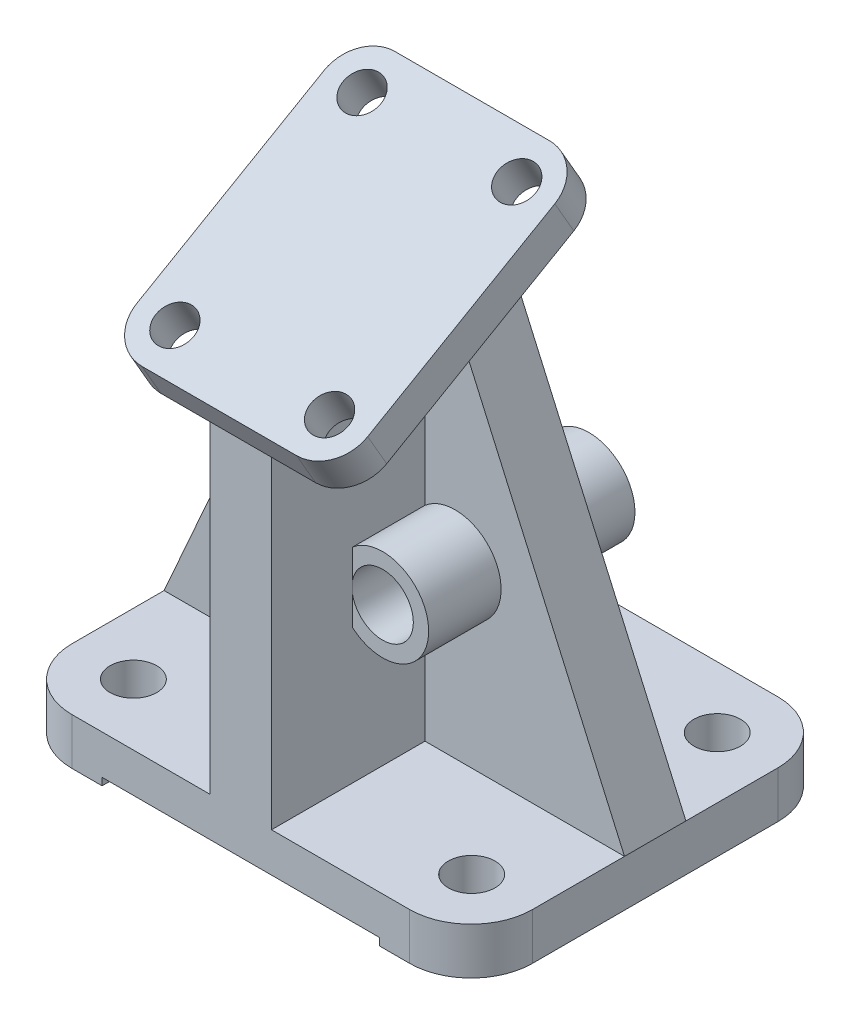
from build123d import *

# Parameters (mm, degrees)
CROQUIS3_W               = 95.25
CROQUIS3_H               = 76.2
SALIENTE_EXTRUIR1_DEPTH  = 9.652
REDONDEO1_R              = 12.7
CROQUIS4_R               = 4.826
CORTAR_EXTRUIR2_DEPTH    = 9.652
CROQUIS6_W               = 12.7
CROQUIS6_H               = 43.017724406
SALIENTE_EXTRUIR3_DEPTH  = 67.564
CROQUIS8_W               = 95.25
CROQUIS8_H               = 12.7
SALIENTE_EXTRUIR4_DEPTH  = 93.218
SALIENTE_EXTRUIR10_DEPTH = 7.874
CORTAR_EXTRUIR8_DEPTH    = 12.7
CROQUIS14_R              = 9.525
SALIENTE_EXTRUIR7_DEPTH  = 14.986
CROQUIS16_R              = 9.525
SALIENTE_EXTRUIR8_DEPTH  = 27.686
CROQUIS17_R              = 6.35
CORTAR_EXTRUIR10_DEPTH   = 60.436
CORTAR_EXTRUIR13_DEPTH   = 12.7
REDONDEO3_R              = 7.874
CROQUIS24_R              = 3.937
CORTAR_EXTRUIR14_DEPTH   = 12.7
CROQUIS25_W              = 12.7
CROQUIS25_H              = 21.99844938
SALIENTE_EXTRUIR11_DEPTH = 31.75
CORTAR_EXTRUIR15_DEPTH   = 31.75
CROQUIS27_W              = 57.404
CROQUIS27_H              = 1.524
CORTAR_EXTRUIR16_DEPTH   = 77.2


with BuildPart() as part:
    # Croquis3 → Saliente-Extruir1 (new body)
    with BuildSketch(Plane(origin=(0, 0, 0), x_dir=(1, 0, 0), z_dir=(0, 1, 0))):
        Rectangle(CROQUIS3_W, CROQUIS3_H)
    extrude(amount=SALIENTE_EXTRUIR1_DEPTH)

    # Redondeo1
    redondeo1_edges = [part.edges().sort_by_distance(p)[0] for p in [
        (47.625, 4.826, 38.1),
        (-47.625, 4.826, 38.1),
        (-47.625, 4.826, -38.1),
        (47.625, 4.826, -38.1),
    ]]
    fillet(redondeo1_edges, radius=REDONDEO1_R)

    # Croquis4 → Cortar-Extruir2 (cut)
    with BuildSketch(Plane(origin=(0, 9.652, 0), x_dir=(1, 0, 0), z_dir=(0, 1, 0))):
        with Locations((-34.925, -25.4)):
            Circle(CROQUIS4_R)
        with Locations((35.052, -25.4)):
            Circle(CROQUIS4_R)
        with Locations((35.052, 25.4)):
            Circle(CROQUIS4_R)
        with Locations((-34.925, 25.4)):
            Circle(CROQUIS4_R)
    extrude(amount=-CORTAR_EXTRUIR2_DEPTH, mode=Mode.SUBTRACT)

    # Croquis6 → Saliente-Extruir3 (add)
    with BuildSketch(Plane(origin=(0, 9.652, 0), x_dir=(1, 0, 0), z_dir=(0, 1, 0))):
        with Locations((0, -16.591137797)):
            Rectangle(CROQUIS6_W, CROQUIS6_H)
    extrude(amount=SALIENTE_EXTRUIR3_DEPTH)

    # Croquis8 → Saliente-Extruir4 (add)
    with BuildSketch(Plane(origin=(0, 9.652, 0), x_dir=(1, 0, 0), z_dir=(0, 1, 0))):
        Rectangle(CROQUIS8_W, CROQUIS8_H)
    extrude(amount=SALIENTE_EXTRUIR4_DEPTH)

    # Croquis11 → Cortar-Extruir8 (cut)
    with BuildSketch(Plane(origin=(0, 0, -6.35), x_dir=(-1, 0, 0), z_dir=(0, 0, -1))):
        Polygon((-6.35, 102.87), (-47.625, 9.652), (-47.625, 102.87), align=None)
    extrude(amount=-CORTAR_EXTRUIR8_DEPTH, mode=Mode.SUBTRACT)

    # Croquis14 → Saliente-Extruir7 (add)
    with BuildSketch(Plane.XY.offset(6.35)):
        with Locations((12.573, 44.704)):
            Circle(CROQUIS14_R)
    extrude(amount=SALIENTE_EXTRUIR7_DEPTH)

    # Croquis16 → Saliente-Extruir8 (add)
    with BuildSketch(Plane.XY.offset(6.35)):
        with Locations((12.573, 44.704)):
            Circle(CROQUIS16_R)
    extrude(amount=-SALIENTE_EXTRUIR8_DEPTH)

    # Croquis17 → Cortar-Extruir10 (cut, through all)
    with BuildSketch(Plane.XY.offset(21.336)):
        with Locations((12.573, 44.704)):
            Circle(CROQUIS17_R)
    extrude(amount=-CORTAR_EXTRUIR10_DEPTH, mode=Mode.SUBTRACT)

    # Croquis13 → Cortar-Extruir13 (cut)
    with BuildSketch(Plane(origin=(0, 0, -6.35), x_dir=(-1, 0, 0), z_dir=(0, 0, -1))):
        Polygon((6.35, 102.87), (47.625, 9.652), (47.625, 102.87), align=None)
    extrude(amount=-CORTAR_EXTRUIR13_DEPTH, mode=Mode.SUBTRACT)



with BuildPart() as body_2:
    # Croquis23 → Saliente-Extruir10 (new body)
    with BuildSketch(Plane(origin=(0, 74.409783942, 42.960508789), x_dir=(1, 0, 0), z_dir=(0, 0.866025404, 0.5))):
        Polygon((0, 5.011636093), (23.876, 5.011636093), (23.876, 65.463636093), (-23.876, 65.463636093), (-23.876, 5.011636093), align=None)
    extrude(amount=SALIENTE_EXTRUIR10_DEPTH)

    # Redondeo3
    redondeo3_edges = [body_2.edges().sort_by_distance(p)[0] for p in [
        (-23.876, 80.325144003, 40.588804619),
        (-23.876, 110.551144003, -11.764163091),
        (23.876, 110.551144003, -11.764163091),
        (23.876, 80.325144003, 40.588804619),
    ]]
    fillet(redondeo3_edges, radius=REDONDEO3_R)

    # Croquis24 → Cortar-Extruir14 (cut)
    with BuildSketch(Plane(origin=(0, 81.228867971, 46.897508789), x_dir=(1, 0, 0), z_dir=(0, 0.866025404, 0.5))):
        with Locations((-16.002, 12.885636093)):
            Circle(CROQUIS24_R)
        with Locations((16.002, 12.885636093)):
            Circle(CROQUIS24_R)
        with Locations((-16.002, 57.589636093)):
            Circle(CROQUIS24_R)
        with Locations((16.002, 57.589636093)):
            Circle(CROQUIS24_R)
    extrude(amount=-CORTAR_EXTRUIR14_DEPTH, mode=Mode.SUBTRACT)


with BuildPart() as part_1:
    add(part.part)

    add(body_2.part)  # Saliente-Extruir11 merges body 2
    # Croquis25 → Saliente-Extruir11 (add)
    with BuildSketch(Plane.XY.offset(6.35)):
        with Locations((0, 88.21522469)):
            Rectangle(CROQUIS25_W, CROQUIS25_H)
    extrude(amount=SALIENTE_EXTRUIR11_DEPTH)

    # Croquis26 → Cortar-Extruir15 (cut)
    with BuildSketch(Plane(origin=(6.35, 0, 0), x_dir=(0, 0, -1), z_dir=(1, 0, 0))):
        Polygon((-15.745567986, 99.21444938), (-38.1, 99.21444938), (-38.1, 86.308112039), align=None)
    extrude(amount=-CORTAR_EXTRUIR15_DEPTH, mode=Mode.SUBTRACT)

    # Croquis27 → Cortar-Extruir16 (cut, through all)
    with BuildSketch(Plane.XY.offset(38.1)):
        with Locations((0, 0.762)):
            Rectangle(CROQUIS27_W, CROQUIS27_H)
    extrude(amount=-CORTAR_EXTRUIR16_DEPTH, mode=Mode.SUBTRACT)


solid = part_1.part
